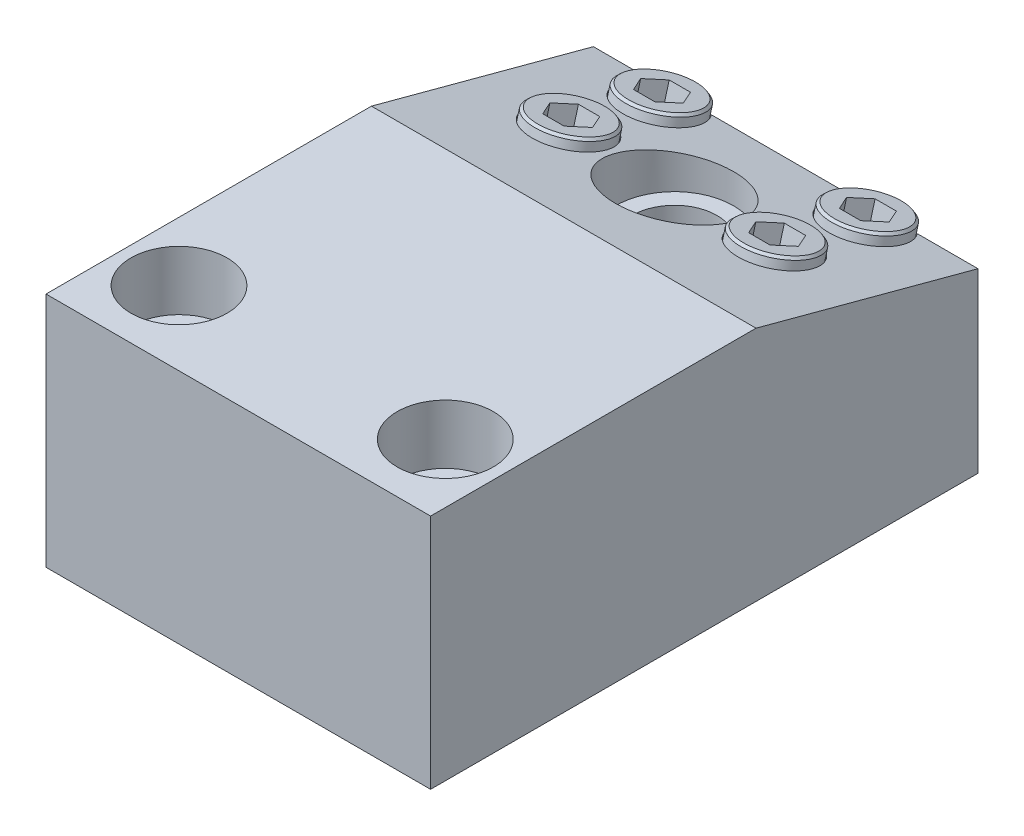
from build123d import *

# Parameters (mm, degrees)
EXTRUDE1_DEPTH      = 20.6375
EXTRUDE1_DEPTH_BACK = 20.6375
CUT_EXTRUDE1_REACH  = 27.4
SKETCH4_R           = 7.9121
SKETCH4_R_2         = 4.3688
EXTRUDE2_DEPTH      = 9.144
EXTRUDE3_DEPTH      = 7.9375
EXTRUDE3_DEPTH_BACK = 7.9375
CUT_EXTRUDE2_DEPTH  = 24.765
LPATTERN2_COUNT     = 3
LPATTERN2_PITCH     = 1.5875
FILLET1_R           = 0.7874
SKETCH8_R           = 1.5875
HOLE1_AT_2_COUNT    = 2
HOLE1_AT_2_PITCH    = 28.575
SKETCH11_R          = 4.0386
CUT_EXTRUDE3_DEPTH  = 3.7084
SKETCH12_R          = 3.9624
BOSS_EXTRUDE1_DEPTH = 4.826
CUT_EXTRUDE4_DEPTH  = 2.286
CHAMFER1_SIZE       = 0.254


with BuildPart() as part:
    # Sketch1 → Extrude1 (new body, two sides)
    with BuildSketch(Plane(origin=(0, 0, 0), x_dir=(0, 0, -1), z_dir=(1, 0, 0))) as extrude1_sk:
        Polygon((34.925, 25.4), (58.748015024, 19.016642363), (58.748015024, 12.442638617), (61.1124, 11.809103573), (61.1124, 0), (0, 0), (0, 25.4), align=None)
    extrude(amount=EXTRUDE1_DEPTH)
    extrude(extrude1_sk.sketch, amount=-EXTRUDE1_DEPTH_BACK)

    # Cut-Extrude1: up to this plane
    cut_extrude1_end = Plane(origin=(-20.6375, 12.442638617, -58.748015024), z_dir=(0, 0.965925826, -0.258819045))
    # Sketch2 → Cut-Extrude1 (cut, up to the surface)
    with BuildSketch(Plane.XZ, mode=Mode.PRIVATE) as cut_extrude1_sk1:
        with BuildLine():
            Line((20.6375, -61.1124), (12.7, -61.1124))
            ThreePointArc((12.7, -61.1124), (14.903540797, -59.369526768), (17.643417126, -58.748015024))
            Line((17.643417126, -58.748015024), (20.6375, -58.748015024))
            Line((20.6375, -58.748015024), (20.6375, -61.1124))
        make_face()
    cut_extrude1_tool1 = split(extrude(cut_extrude1_sk1.sketch, amount=-CUT_EXTRUDE1_REACH, mode=Mode.PRIVATE), bisect_by=cut_extrude1_end, keep=Keep.BOTH, mode=Mode.PRIVATE)
    add(cut_extrude1_tool1.solids().sort_by_distance((17.318219, 0, -60.047597))[0], mode=Mode.SUBTRACT)
    # Sketch2 → Cut-Extrude1 (cut, up to the surface)
    with BuildSketch(Plane.XZ, mode=Mode.PRIVATE) as cut_extrude1_sk2:
        with BuildLine():
            Line((-20.6375, -58.748015024), (-17.643417126, -58.748015024))
            ThreePointArc((-17.643417126, -58.748015024), (-14.903540797, -59.369526768), (-12.7, -61.1124))
            Line((-12.7, -61.1124), (-20.6375, -61.1124))
            Line((-20.6375, -61.1124), (-20.6375, -58.748015024))
        make_face()
    cut_extrude1_tool2 = split(extrude(cut_extrude1_sk2.sketch, amount=-CUT_EXTRUDE1_REACH, mode=Mode.PRIVATE), bisect_by=cut_extrude1_end, keep=Keep.BOTH, mode=Mode.PRIVATE)
    add(cut_extrude1_tool2.solids().sort_by_distance((-17.318219, 0, -60.047597))[0], mode=Mode.SUBTRACT)

    # Sketch3 → Cut-Revolve1 (revolve, cut)
    with BuildSketch(Plane(origin=(0, 0, 0), x_dir=(0, 0, -1), z_dir=(1, 0, 0)), mode=Mode.PRIVATE) as cut_revolve1_sk:
        Polygon((40.4622, 23.916311732), (40.4622, 17.338356988), (42.2529, 17.338356988), (42.2529, 3.175), (38.8366, 3.175), (38.8366, 0), (46.8122, 0), (46.8122, 23.916311732), align=None)
    revolve(cut_revolve1_sk.sketch.rotate(Axis((0, -4.910727806, -46.8122), (0, 1, 0)), 180), axis=Axis((0, -4.910727806, -46.8122), (0, 1, 0)), mode=Mode.SUBTRACT)  # turned: the seam where the file's is

    # Sketch4 → Extrude2 (add)
    with BuildSketch(Plane.XZ.offset(-3.175)):
        with Locations(Location((0, -46.8122, 0), (0, 0, 270))):  # turned: the seam where the file's is
            Circle(SKETCH4_R)
        with Locations(Location((0, -46.8122, 0), (0, 0, 270))):  # turned: the seam where the file's is
            Circle(SKETCH4_R_2, mode=Mode.SUBTRACT)
    extrude(amount=EXTRUDE2_DEPTH)

    # S2D0005 → Cut-Revolve2 (revolve, cut)
    with BuildSketch(Plane(origin=(0, 0, -7.9248), x_dir=(-1, 0, 0), z_dir=(0, 0, 1)), mode=Mode.PRIVATE) as cut_revolve2_sk:
        Polygon((0, 0), (6.35, 0), (6.35, -2.667), (1.5875, -2.667), (1.5875, -6.35), (0, -6.35), align=None)
    revolve(cut_revolve2_sk.sketch.rotate(Axis((0, 10.867513557, -7.9248), (0, -1, 0)), 270), axis=Axis((0, 10.867513557, -7.9248), (0, -1, 0)), mode=Mode.SUBTRACT)  # turned: the seam where the file's is

    # Sketch6 → Extrude3 (add, two sides)
    with BuildSketch(Plane(origin=(0, 0, 0), x_dir=(0, 0, -1), z_dir=(1, 0, 0))) as extrude3_sk:
        Polygon((61.1124, 2.789570434), (65.8876, 1.51005945), (65.8876, 8.136655225), (61.1124, 9.416166209), align=None)
    extrude(amount=EXTRUDE3_DEPTH)
    extrude(extrude3_sk.sketch, amount=-EXTRUDE3_DEPTH_BACK)

    # Sketch7 → Cut-Extrude2 (cut, symmetric)
    with BuildSketch(Plane(origin=(0, 0, 0), x_dir=(0, 0, -1), z_dir=(1, 0, 0))):
        Polygon((65.8876, 3.49443445), (65.8876, 2.70068445), (65.09385, 2.913369121), (65.09385, 3.281749778), align=None)
    cut_extrude2 = extrude(amount=CUT_EXTRUDE2_DEPTH, both=True, mode=Mode.SUBTRACT)

    # LPattern2: Cut-Extrude2 ×3
    with Locations(*[(0, i * LPATTERN2_PITCH, 0) for i in range(1, LPATTERN2_COUNT)]):
        add(cut_extrude2, mode=Mode.SUBTRACT)

    # Fillet1
    fillet1_edges = [part.edges().sort_by_distance(p)[0] for p in [
        (0, 8.136655225, -65.8876),
        (0, 1.51005945, -65.8876),
    ]]
    fillet(fillet1_edges, radius=FILLET1_R)

    # Sketch9 → Hole1 (revolve, cut)
    with BuildSketch(Plane(origin=(-14.2875, 25.4, -7.9248), x_dir=(0, 0, 1), z_dir=(1, 0, 0))):
        Polygon((0, 0), (0, 31.369), (3.5687, 31.369), (3.5687, 6.35), (5.1562, 6.35), (5.1562, 0), align=None)
    hole1 = revolve(axis=Axis((-14.2875, -84.6, -7.9248), (0, 1, 0)), mode=Mode.SUBTRACT)

    # Hole1 at 2: Hole1 ×2
    with Locations(*[(i * HOLE1_AT_2_PITCH, 0, 0) for i in range(1, HOLE1_AT_2_COUNT)]):
        add(hole1, mode=Mode.SUBTRACT)

    # Sketch11 → Cut-Extrude3 (cut)
    with BuildSketch(Plane(origin=(0, 32.429772628, -8.689531386), x_dir=(1, 0, 0), z_dir=(0, 0.965925826, -0.258819045))):
        with Locations((-11.1125, 49.284355738)):
            Circle(SKETCH11_R)
        with Locations(Location((-11.1125, 39.200555738, 0), (0, 0, 270))):  # turned: the seam where the file's is
            Circle(SKETCH11_R)
        with Locations((10.9855, 49.284355738)):
            Circle(SKETCH11_R)
        with Locations(Location((10.9855, 39.200555738, 0), (0, 0, 270))):  # turned: the seam where the file's is
            Circle(SKETCH11_R)
    extrude(amount=-CUT_EXTRUDE3_DEPTH, mode=Mode.SUBTRACT)

    # Sketch12 → Boss-Extrude1 (add)
    with BuildSketch(Plane(origin=(0, 28.847733294, -7.72972684), x_dir=(1, 0, 0), z_dir=(0, 0.965925826, -0.258819045))):
        with Locations(Location((-11.1125, 49.284355738, 0), (0, 0, 63.100135956))):  # turned: the seam where the file's is
            Circle(SKETCH12_R)
        with Locations(Location((-11.1125, 39.200555738, 0), (0, 0, 270))):  # turned: the seam where the file's is
            Circle(SKETCH12_R)
        with Locations(Location((10.9855, 49.284355738, 0), (0, 0, 116.899864044))):  # turned: the seam where the file's is
            Circle(SKETCH12_R)
        with Locations(Location((10.9855, 39.200555738, 0), (0, 0, 270))):  # turned: the seam where the file's is
            Circle(SKETCH12_R)
    extrude(amount=BOSS_EXTRUDE1_DEPTH)

    # Sketch13 → Cut-Extrude4 (cut)
    with BuildSketch(Plane(origin=(0, 33.509291332, -8.978787551), x_dir=(1, 0, 0), z_dir=(0, 0.965925826, -0.258819045))):
        Polygon((-12.256346353, 51.265555738), (-9.968653647, 51.265555738), (-8.824807293, 49.284355738), (-9.968653647, 47.303155738), (-12.256346353, 47.303155738), (-13.400192707, 49.284355738), align=None)
        Polygon((-12.256346353, 41.181755738), (-9.968653647, 41.181755738), (-8.824807293, 39.200555738), (-9.968653647, 37.219355738), (-12.256346353, 37.219355738), (-13.400192707, 39.200555738), align=None)
        Polygon((9.841653647, 51.265555738), (12.129346353, 51.265555738), (13.273192707, 49.284355738), (12.129346353, 47.303155738), (9.841653647, 47.303155738), (8.697807293, 49.284355738), align=None)
        Polygon((9.841653647, 41.181755738), (12.129346353, 41.181755738), (13.273192707, 39.200555738), (12.129346353, 37.219355738), (9.841653647, 37.219355738), (8.697807293, 39.200555738), align=None)
    extrude(amount=-CUT_EXTRUDE4_DEPTH, mode=Mode.SUBTRACT)

    # Chamfer1
    chamfer1_edges = [part.edges().sort_by_distance(p)[0] for p in [
        (-12.905218907, 21.668140669, -53.170563444),
        (-11.1125, 22.337896344, -50.671001237),
        (12.778218907, 21.668140669, -53.170563444),
        (10.9855, 22.337896344, -50.671001237),
    ]]
    chamfer(chamfer1_edges, length=CHAMFER1_SIZE)


with BuildPart() as body_2:
    # Sketch8 → Revolve1 (revolve)
    with BuildSketch(Plane(origin=(0, 0, 0), x_dir=(0, 0, -1), z_dir=(1, 0, 0)), mode=Mode.PRIVATE) as revolve1_sk:
        with Locations((12.6873, 1.0795)):
            Circle(SKETCH8_R)
    revolve(revolve1_sk.sketch.rotate(Axis((0, -0.66675, -7.9248), (0, 1, 0)), 180), axis=Axis((0, -0.66675, -7.9248), (0, 1, 0)))  # turned: the seam where the file's is


solid = Compound([part.part, body_2.part])
